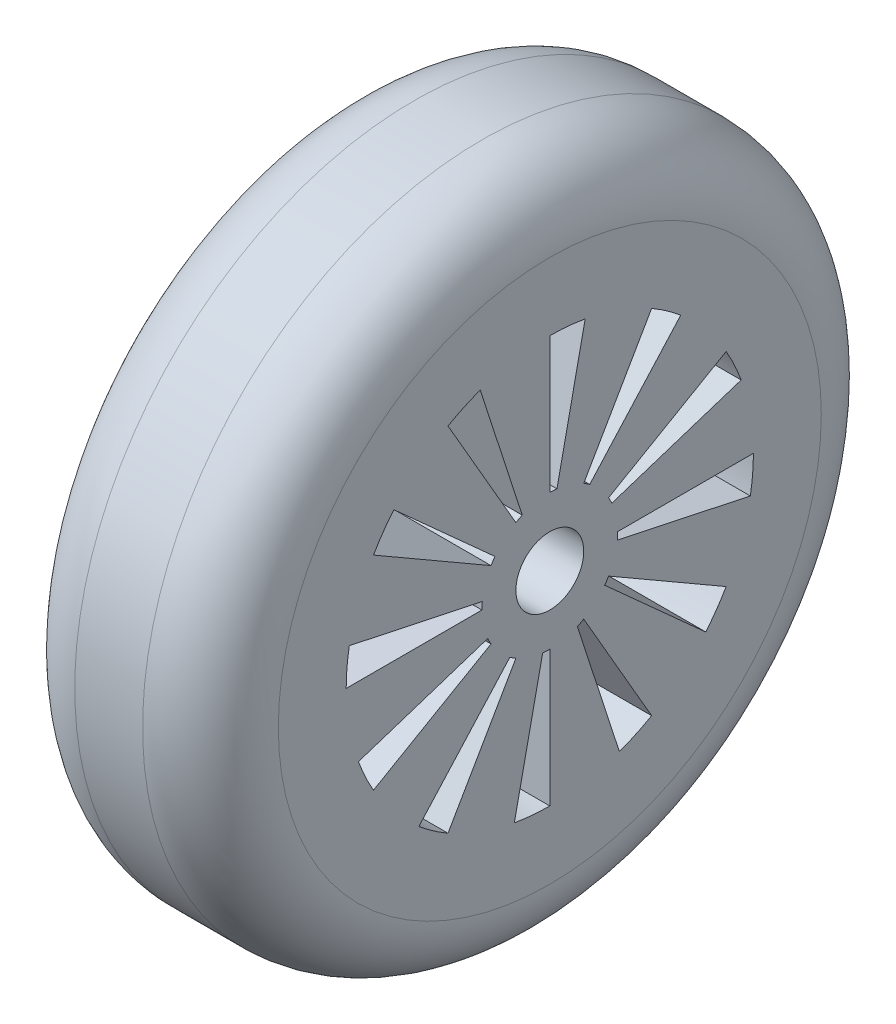
from build123d import *

# Parameters (mm, degrees)
SKETCH1_R           = 50
BOSS_EXTRUDE1_DEPTH = 30
SKETCH2_R           = 5
CUT_EXTRUDE1_DEPTH  = 31
CUT_EXTRUDE10_DEPTH = 31
CIRPATTERN1_COUNT   = 12
FILLET1_R           = 10


with BuildPart() as part:
    # Sketch1 → Boss-Extrude1 (new body)
    with BuildSketch(Plane(origin=(0, 0, 0), x_dir=(0, 0, -1), z_dir=(1, 0, 0))):
        Circle(SKETCH1_R)
    extrude(amount=BOSS_EXTRUDE1_DEPTH)

    # Sketch2 → Cut-Extrude1 (cut, through all)
    with BuildSketch(Plane(origin=(30, 0, 0), x_dir=(0, 0, -1), z_dir=(1, 0, 0))):
        Circle(SKETCH2_R)
    extrude(amount=-CUT_EXTRUDE1_DEPTH, mode=Mode.SUBTRACT)

    # Sketch3 → Cut-Extrude10 (cut, through all)
    with BuildSketch(Plane(origin=(30, 0, 0), x_dir=(0, 0, -1), z_dir=(1, 0, 0))):
        with BuildLine():
            Line((0, -30), (0, -10))
            ThreePointArc((0, -10), (-0.526234368, -9.98614427), (-1.051010465, -9.944615478))
            Line((-1.051010465, -9.944615478), (-5.216763219, -29.542941315))
            ThreePointArc((-5.216763219, -29.542941315), (-2.618373595, -29.885516889), (0, -30))
        make_face()
    cut_extrude10 = extrude(amount=-CUT_EXTRUDE10_DEPTH, mode=Mode.SUBTRACT)

    # CirPattern1: Cut-Extrude10 ×12 about axis
    cirpattern1_axis = Axis((0, 0, 0), (1, 0, 0))
    for i in range(1, CIRPATTERN1_COUNT):
        add(cut_extrude10.rotate(cirpattern1_axis, i * 360 / CIRPATTERN1_COUNT), mode=Mode.SUBTRACT)

    # Fillet1
    fillet1_edges = [part.edges().sort_by_distance(p)[0] for p in [
        (0, 0, 50),
        (30, 0, 50),
    ]]
    fillet(fillet1_edges, radius=FILLET1_R)


solid = part.part
